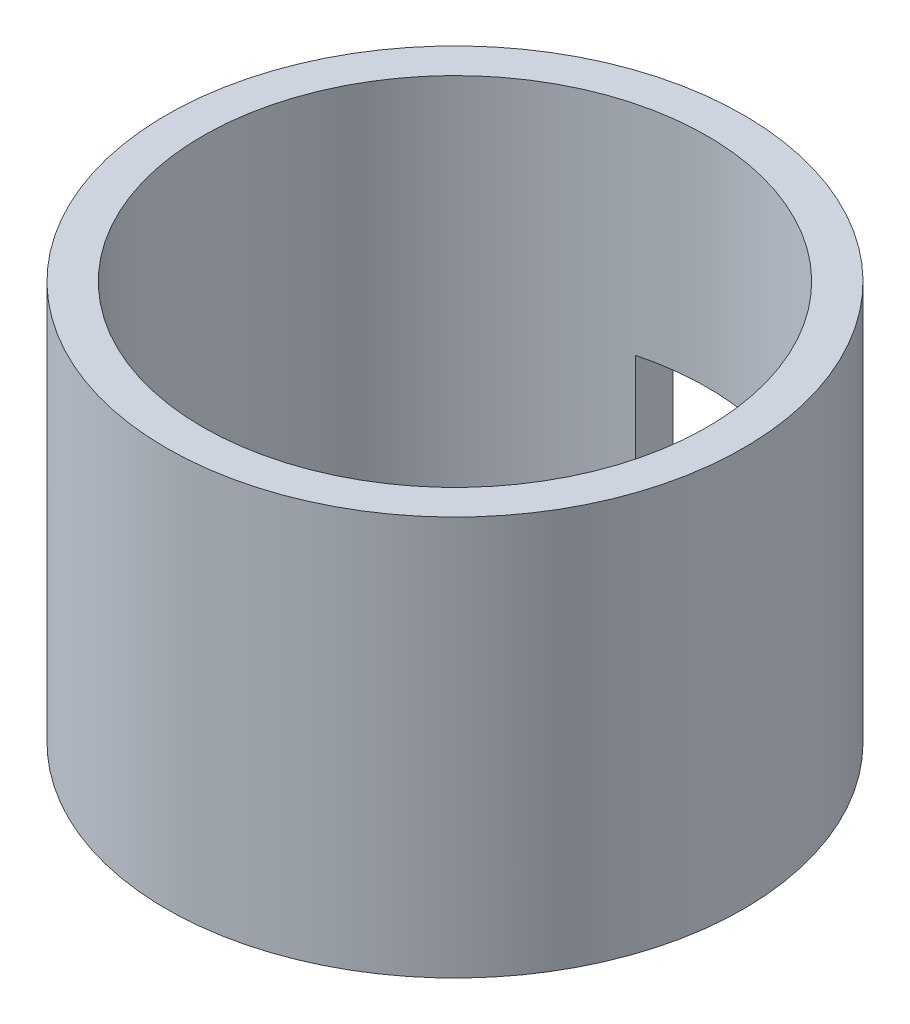
from build123d import *

# Parameters (mm, degrees)
CROQUIS1_R              = 15.9
CROQUIS1_R_2            = 13.9
SALIENTE_EXTRUIR1_DEPTH = 22
CROQUIS2_W              = 7
CROQUIS2_H              = 20
CORTAR_EXTRUIR1_DEPTH   = 22


with BuildPart() as part:
    # Croquis1 → Saliente-Extruir1 (new body)
    with BuildSketch(Plane(origin=(0, 0, 0), x_dir=(1, 0, 0), z_dir=(0, 1, 0))):
        Circle(CROQUIS1_R)
        Circle(CROQUIS1_R_2, mode=Mode.SUBTRACT)
    extrude(amount=SALIENTE_EXTRUIR1_DEPTH)

    # Croquis2 → Cortar-Extruir1 (cut)
    with BuildSketch(Plane.XY):
        Rectangle(CROQUIS2_W, CROQUIS2_H)
    extrude(amount=-CORTAR_EXTRUIR1_DEPTH, mode=Mode.SUBTRACT)


solid = part.part
